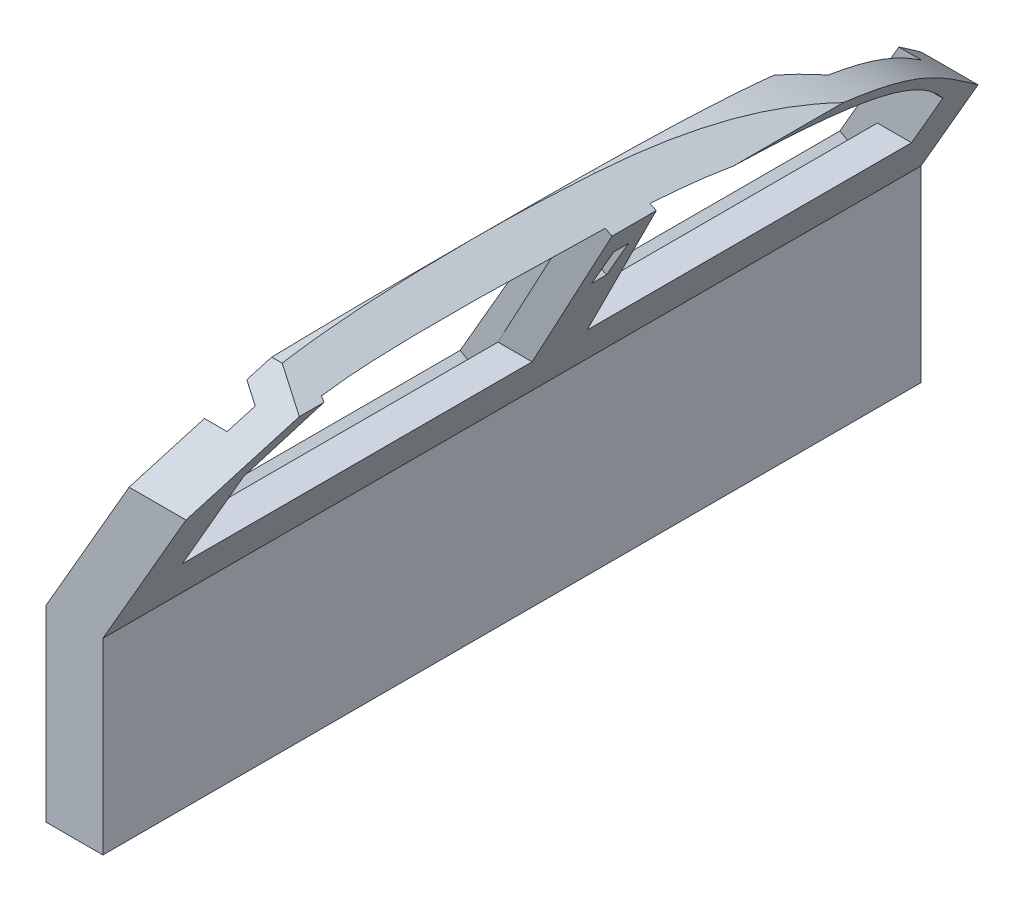
from build123d import *

# Parameters (mm, degrees)
EXTRUDE_1_DEPTH          = 300
CUT_EXTRUDE_1_DEPTH      = 1.0000001
CUT_EXTRUDE_1_DEPTH_BACK = 831.0000001
SKETCH_4_W               = 15
SKETCH_4_H               = 45
CUT_EXTRUDE_2_DEPTH      = 258.720162759
SKETCH_4_3_W             = 15
SKETCH_4_3_H             = 45
CUT_EXTRUDE_3_DEPTH      = 20


with BuildPart() as part:
    # 스케치1 → 보스-돌출1 (new body)
    with BuildSketch(Plane(origin=(0, 0, 0), x_dir=(0, 0, -1), z_dir=(1, 0, 0))):
        with BuildLine():
            Line((-41.993007726, 32.892860384), (-41.993007726, -303.619075042))
            Line((-41.993007726, -303.619075042), (788.006992274, -303.619075042))
            Line((788.006992274, -303.619075042), (788.006992274, -12.90547458))
            add(Edge.make_bspline(
                [(788.006992274, -12.90547458), (680.261509472, 78.254339674), (631.210016853, 128.415858034), (368.750142796, 135.255878696)],
                knots=[0, 0, 0, 0, 1, 1, 1, 1], degree=3))
            add(Edge.make_bspline(
                [(45.325655749, 132.198658827), (134.989620851, 137.211386353), (265.463569923, 138.011524869), (368.750142796, 135.255878696)],
                knots=[0, 0, 0, 0, 1, 1, 1, 1], degree=3))
            Line((45.325655749, 132.198658827), (-41.993007726, 32.892860384))
        make_face()
        with BuildLine():
            Line((4.116595834, 54.214584045), (54.427658026, 114.389853292))
            add(Edge.make_bspline(
                [(54.427658026, 114.389853292), (122.914694658, 118.068796405), (254.727094278, 116.434615788), (344.321994749, 115.599177573)],
                knots=[0, 0, 0, 0, 0.843637698, 0.843637698, 0.843637698, 0.843637698], degree=3))
            Line((344.321994749, 115.599177573), (359.116595834, -53.619075042))
            Line((359.116595834, -53.619075042), (4.116595834, -53.619075042))
            Line((4.116595834, -53.619075042), (4.116595834, 54.214584045))
        make_face(mode=Mode.SUBTRACT)
        with BuildLine():
            Line((414.932922958, -53.619075042), (389.116595834, 115.255878696))
            add(Edge.make_bspline(
                [(389.116595834, 115.255878696), (584.597474826, 110.825479528), (668.447748965, 84.913988672), (744.116595834, 1.380924958)],
                knots=[0.027735734, 0.027735734, 0.027735734, 0.027735734, 0.842070206, 0.842070206, 0.842070206, 0.842070206], degree=3))
            Line((744.116595834, 1.380924958), (744.116595834, -53.619075042))
            Line((744.116595834, -53.619075042), (414.932922958, -53.619075042))
        make_face(mode=Mode.SUBTRACT)
    extrude(amount=EXTRUDE_1_DEPTH)

    # 스케치2 → 컷-돌출1 (cut, two sides)
    with BuildSketch(Plane.XY.offset(41.993007726)) as cut_extrude_1_sk:
        Polygon((179.652203691, 32.892860384), (239.655287588, 136.821250303), (282.956557777, 111.821250303), (237.38723061, 32.892860384), (300, 32.892860384), (300, -303.619075042), (341.364714008, -303.619075042), (341.364714008, 251.457374482), (0, 251.457374482), (0, 32.892860384), align=None)
        Polygon((95.31772029, -113.178749697), (179.652203691, 32.892860384), (0, 32.892860384), (0, -303.619075042), (95.31772029, -303.619075042), align=None)
        Polygon((300, 32.892860384), (237.38723061, 32.892860384), (153.052747209, -113.178749697), (153.052747209, -303.619075042), (300, -303.619075042), align=None)
    extrude(amount=CUT_EXTRUDE_1_DEPTH, mode=Mode.SUBTRACT)
    extrude(cut_extrude_1_sk.sketch, amount=-CUT_EXTRUDE_1_DEPTH_BACK, mode=Mode.SUBTRACT)

    # 스케치4 → 컷-돌출2 (cut, through all)
    with BuildSketch(Plane(origin=(120.496126421, -69.568471025, 0), x_dir=(0, 0, 1), z_dir=(-0.866025404, 0.5, 0))):
        with Locations((-374.116595834, 175.489898801)):
            Rectangle(SKETCH_4_W, SKETCH_4_H)
    extrude(amount=-CUT_EXTRUDE_2_DEPTH, mode=Mode.SUBTRACT)

    # 스케치4<3> → 컷-돌출3 (cut)
    with BuildSketch(Plane(origin=(120.496126421, -69.568471025, 0), x_dir=(0, 0, 1), z_dir=(-0.866025404, 0.5, 0))):
        Polygon((-744.116595834, 18.416776129), (-744.116595834, 213.416776129), (-389.116595834, 213.416776129), (-389.116595834, 17.989898801), (-389.116595834, -11.583223871), (-744.116595834, -11.583223871), align=None)
        Polygon((-359.116595834, 18.416776129), (-359.116595834, 212.989898801), (-4.116595834, 212.989898801), (-4.116595834, 17.989898801), (-4.116595834, -12.010101199), (-359.116595834, -12.010101199), align=None)
        with Locations((-374.116595834, 175.489898801)):
            Rectangle(SKETCH_4_3_W, SKETCH_4_3_H)
    extrude(amount=-CUT_EXTRUDE_3_DEPTH, mode=Mode.SUBTRACT)


solid = part.part
